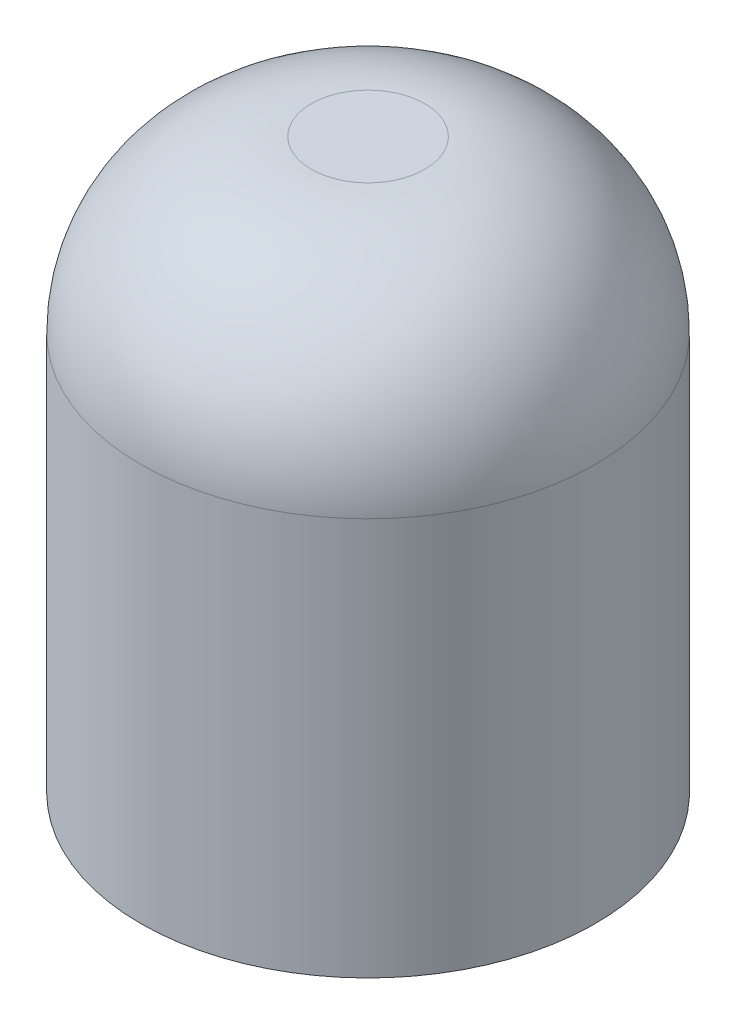
from build123d import *

# Parameters (mm, degrees)
SKETCH1_R           = 4
BOSS_EXTRUDE1_DEPTH = 10
FILLET1_R           = 3
SKETCH2_R           = 1.5
CUT_EXTRUDE1_DEPTH  = 5


with BuildPart() as part:
    # Sketch1 → Boss-Extrude1 (new body)
    with BuildSketch(Plane(origin=(0, 0, 0), x_dir=(1, 0, 0), z_dir=(0, 1, 0))):
        Circle(SKETCH1_R)
    extrude(amount=BOSS_EXTRUDE1_DEPTH)

    # Fillet1
    fillet1_edges = [part.edges().sort_by_distance(p)[0] for p in [
        (-4, 10, 0),
    ]]
    fillet(fillet1_edges, radius=FILLET1_R)

    # Sketch2 → Cut-Extrude1 (cut)
    with BuildSketch(Plane.XZ):
        Circle(SKETCH2_R)
    extrude(amount=-CUT_EXTRUDE1_DEPTH, mode=Mode.SUBTRACT)


solid = part.part
